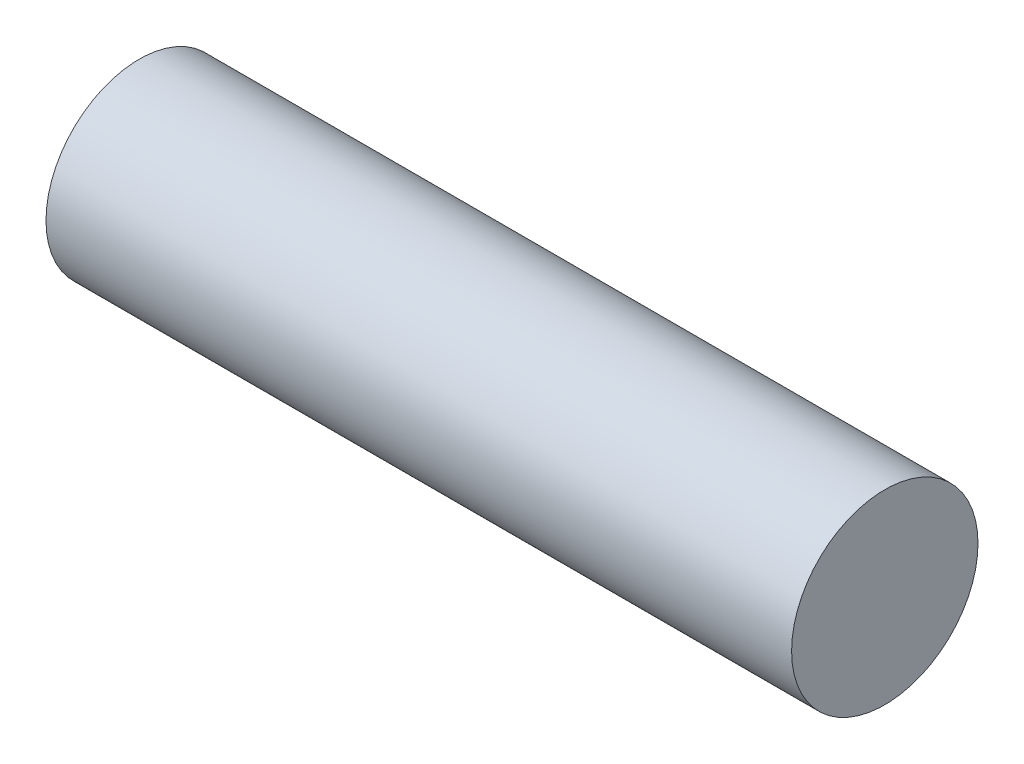
from build123d import *

# Parameters (mm, degrees)
SKETCH1_R           = 6.35
BOSS_EXTRUDE1_DEPTH = 50.8


with BuildPart() as part:
    # Sketch1 → Boss-Extrude1 (new body)
    with BuildSketch(Plane(origin=(0, 0, 0), x_dir=(0, 0, -1), z_dir=(1, 0, 0))):
        Circle(SKETCH1_R)
    extrude(amount=BOSS_EXTRUDE1_DEPTH)


solid = part.part
